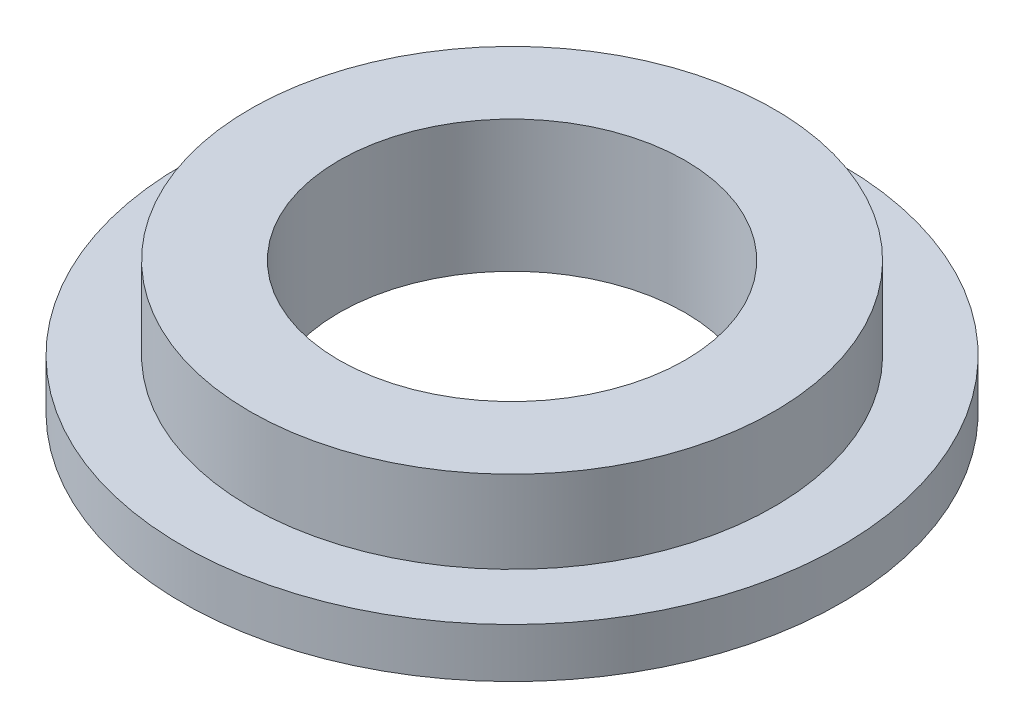
from build123d import *

# Parameters (mm, degrees)
SKETCH_1_R      = 15.9
SKETCH_1_R_2    = 10.5
EXTRUDE_1_DEPTH = 5
SKETCH_2_R      = 20
SKETCH_2_R_2    = 10.5
EXTRUDE_2_DEPTH = 3


with BuildPart() as part:
    # 草图1 → 凸台-拉伸1 (new body)
    with BuildSketch(Plane(origin=(0, 0, 0), x_dir=(1, 0, 0), z_dir=(0, 1, 0))):
        Circle(SKETCH_1_R)
        Circle(SKETCH_1_R_2, mode=Mode.SUBTRACT)
    extrude(amount=EXTRUDE_1_DEPTH)

    # 草图2 → 凸台-拉伸2 (add)
    with BuildSketch(Plane.XZ):
        Circle(SKETCH_2_R)
        Circle(SKETCH_2_R_2, mode=Mode.SUBTRACT)
    extrude(amount=EXTRUDE_2_DEPTH)


solid = part.part
